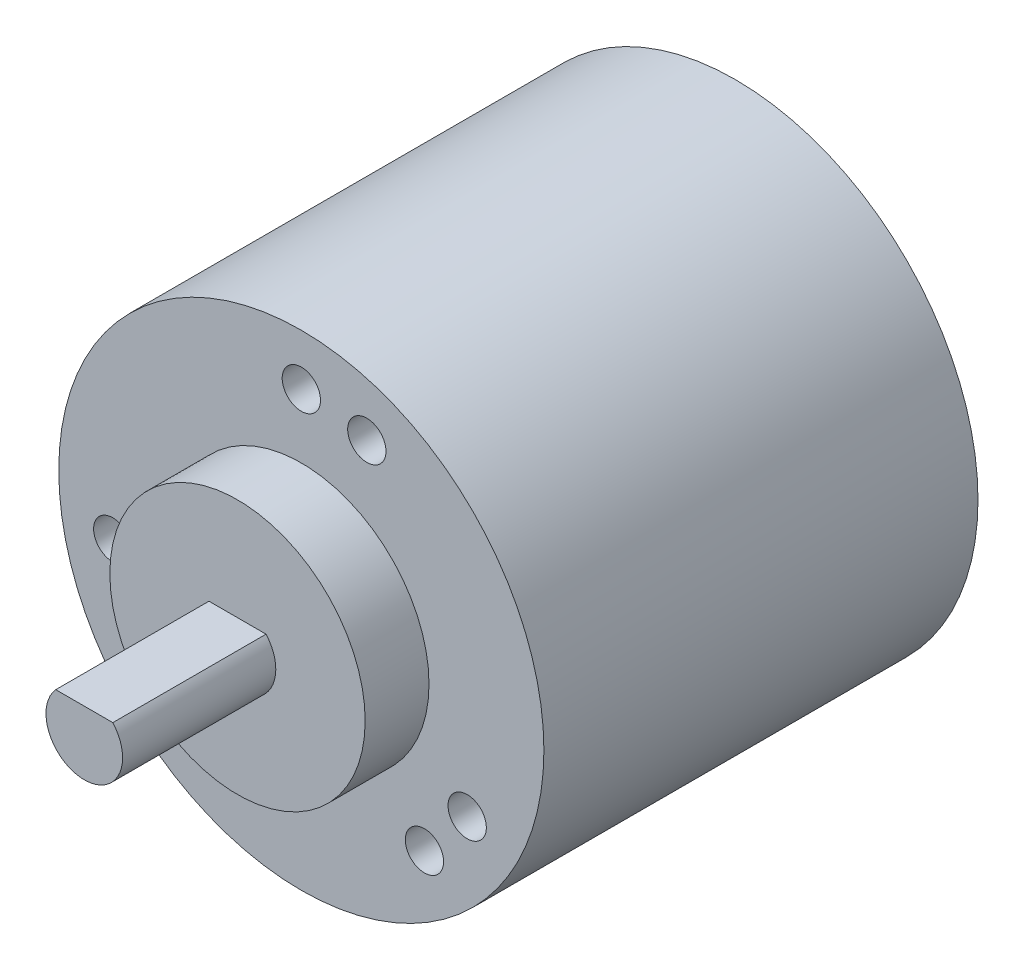
from build123d import *

# Parameters (mm, degrees)
SKETCH1_R           = 19
BOSS_EXTRUDE1_DEPTH = 34
SKETCH2_R           = 1.5
CUT_EXTRUDE1_DEPTH  = 6
SKETCH3_R           = 10
BOSS_EXTRUDE2_DEPTH = 5
BOSS_EXTRUDE3_DEPTH = 12


with BuildPart() as part:
    # Sketch1 → Boss-Extrude1 (new body)
    with BuildSketch(Plane.XY):
        Circle(SKETCH1_R)
    extrude(amount=BOSS_EXTRUDE1_DEPTH)

    # Sketch2 → Cut-Extrude1 (cut)
    with BuildSketch(Plane.XY.offset(34)):
        with Locations((-12.990381057, -7.5)):
            Circle(SKETCH2_R)
        with Locations((-14.772116295, -2.604722665)):
            Circle(SKETCH2_R)
        with Locations((0, 15)):
            Circle(SKETCH2_R)
        with Locations((5.13030215, 14.095389312)):
            Circle(SKETCH2_R)
        with Locations((12.990381057, -7.5)):
            Circle(SKETCH2_R)
        with Locations((9.641814145, -11.490666647)):
            Circle(SKETCH2_R)
    extrude(amount=-CUT_EXTRUDE1_DEPTH, mode=Mode.SUBTRACT)

    # Sketch3 → Boss-Extrude2 (add)
    with BuildSketch(Plane.XY.offset(34)):
        Circle(SKETCH3_R)
    extrude(amount=BOSS_EXTRUDE2_DEPTH)

    # Sketch4 → Boss-Extrude3 (add)
    with BuildSketch(Plane.XY.offset(39)):
        with BuildLine():
            ThreePointArc((3, 0), (2.802517077, 1.070466269), (2.236067977, 2))
            Line((2.236067977, 2), (-2.236067977, 2))
            ThreePointArc((-2.236067977, 2), (-1.070466269, -2.802517077), (3, 0))
        make_face()
    extrude(amount=BOSS_EXTRUDE3_DEPTH)


solid = part.part
